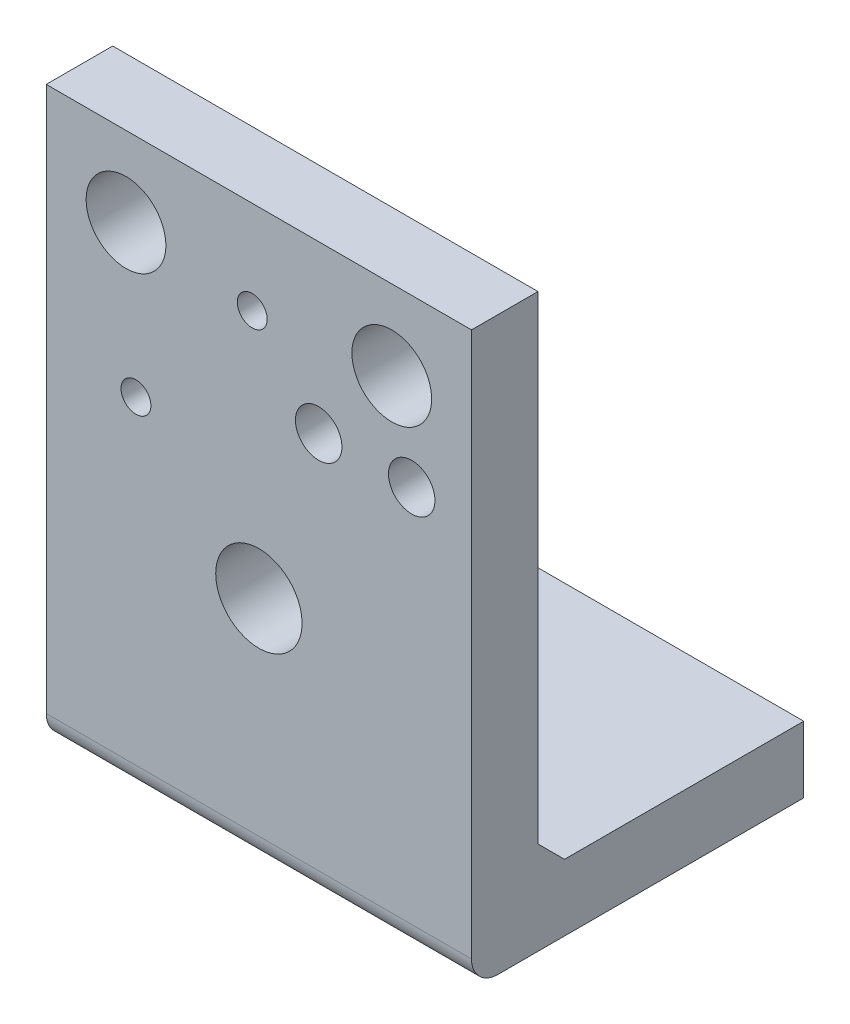
from build123d import *

# Parameters (mm, degrees)
SKETCH1_W           = 64
SKETCH1_H           = 86
BOSS_EXTRUDE1_DEPTH = 10
SKETCH2_W           = 64
SKETCH2_H           = 10
BOSS_EXTRUDE2_DEPTH = 40
SKETCH4_R           = 6
SKETCH4_R_2         = 2.25
SKETCH4_R_3         = 3.5
SKETCH4_R_4         = 6.5
CUT_EXTRUDE1_DEPTH  = 11
SKETCH6_R           = 2
SKETCH6_R_2         = 1.25
CUT_EXTRUDE2_DEPTH  = 11
CHAMFER1_SIZE       = 4
FILLET1_R           = 4


with BuildPart() as part:
    # Sketch1 → Boss-Extrude1 (new body)
    with BuildSketch(Plane.XY):
        Rectangle(SKETCH1_W, SKETCH1_H)
    extrude(amount=BOSS_EXTRUDE1_DEPTH)

    # Sketch2 → Boss-Extrude2 (add)
    with BuildSketch(Plane(origin=(0, 0, 0), x_dir=(-1, 0, 0), z_dir=(0, 0, -1))):
        with Locations((0, -38)):
            Rectangle(SKETCH2_W, SKETCH2_H)
    extrude(amount=BOSS_EXTRUDE2_DEPTH)

    # Sketch4 → Cut-Extrude1 (cut, through all)
    with BuildSketch(Plane(origin=(0, 0, 0), x_dir=(-1, 0, 0), z_dir=(0, 0, -1))):
        with Locations((20, 31)):
            Circle(SKETCH4_R)
        with Locations((1, 29)):
            Circle(SKETCH4_R_2)
        with Locations((-20, 31)):
            Circle(SKETCH4_R)
        with Locations((-9, 18)):
            Circle(SKETCH4_R_3)
        with Locations((-23, 18)):
            Circle(SKETCH4_R_3)
        with Locations((18.5, 9)):
            Circle(SKETCH4_R_2)
        with Locations((0, -8)):
            Circle(SKETCH4_R_4)
    extrude(amount=-CUT_EXTRUDE1_DEPTH, mode=Mode.SUBTRACT)

    # Sketch6 → Cut-Extrude2 (cut, through all)
    with BuildSketch(Plane(origin=(0, -33, 0), x_dir=(1, 0, 0), z_dir=(0, 1, 0))):
        with Locations((0, 16.5)):
            Circle(SKETCH6_R)
        with Locations((5.25, 21.75)):
            Circle(SKETCH6_R_2)
        with Locations((5.25, 11.25)):
            Circle(SKETCH6_R_2)
        with Locations((-5.25, 11.25)):
            Circle(SKETCH6_R_2)
        with Locations((-5.25, 21.75)):
            Circle(SKETCH6_R_2)
        with Locations((-9.545941546, 16.5)):
            Circle(SKETCH6_R)
        with Locations((0, 6.954058454)):
            Circle(SKETCH6_R)
        with Locations((9.545941546, 16.5)):
            Circle(SKETCH6_R)
        with Locations((0, 26.045941546)):
            Circle(SKETCH6_R)
    extrude(amount=-CUT_EXTRUDE2_DEPTH, mode=Mode.SUBTRACT)

    # Chamfer1
    chamfer1_edges = [part.edges().sort_by_distance(p)[0] for p in [
        (0, -33, 0),
    ]]
    chamfer(chamfer1_edges, length=CHAMFER1_SIZE)

    # Fillet1
    fillet1_edges = [part.edges().sort_by_distance(p)[0] for p in [
        (0, -43, 10),
    ]]
    fillet(fillet1_edges, radius=FILLET1_R)


solid = part.part
